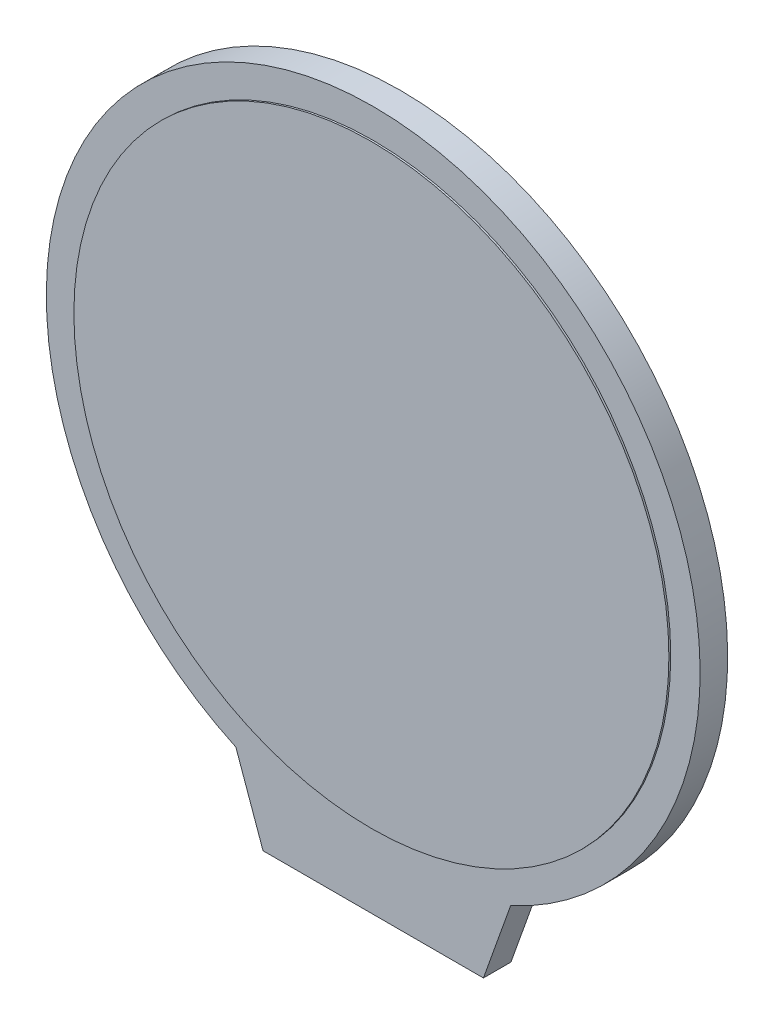
from build123d import *

# Parameters (mm, degrees)
EXTRUDE_1_DEPTH = 1.5
SKETCH_3_R      = 16.2
EXTRUDE_2_DEPTH = 0.1


with BuildPart() as part:
    # 草图2 → 凸台-拉伸1 (new body)
    with BuildSketch(Plane.XY):
        with BuildLine():
            Line((-6, -20.3), (6, -20.3))
            Line((6, -20.3), (7.479773249, -16.152182272))
            ThreePointArc((7.479773249, -16.152182272), (0, 17.8), (-7.479773249, -16.152182272))
            Line((-7.479773249, -16.152182272), (-6, -20.3))
        make_face()
    extrude(amount=EXTRUDE_1_DEPTH)

    # 草图3 → 凸台-拉伸2 (add)
    with BuildSketch(Plane.XY.offset(1.5)):
        Circle(SKETCH_3_R)
    extrude(amount=EXTRUDE_2_DEPTH)


solid = part.part
